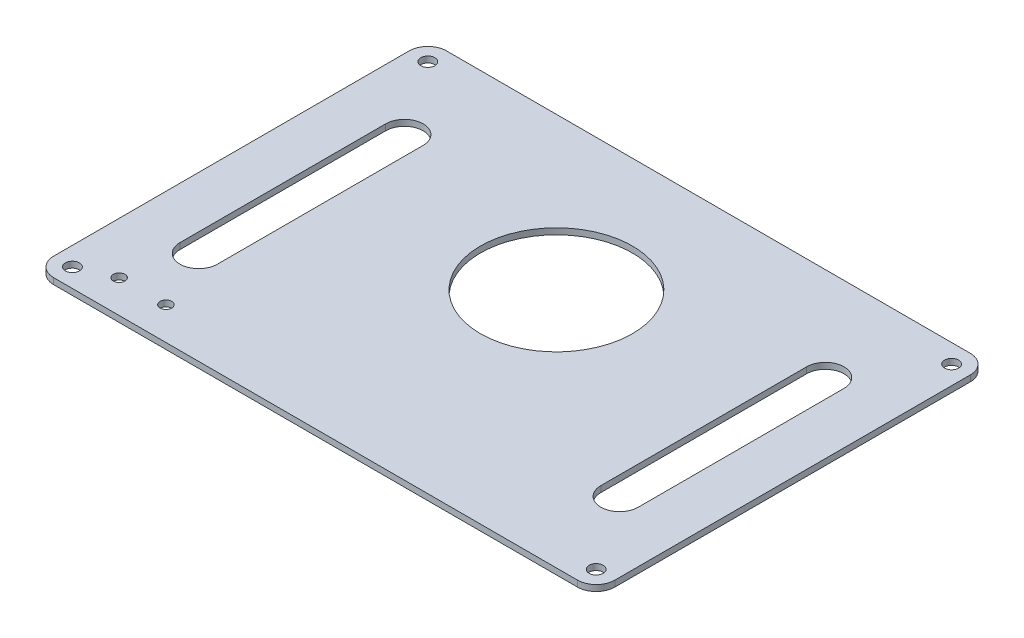
from build123d import *

# Parameters (mm, degrees)
SKETCH1_R           = 1.5
BOSS_EXTRUDE1_DEPTH = 1.3
SKETCH2_R           = 16.25
SKETCH2_R_2         = 1.25
CUT_EXTRUDE1_DEPTH  = 1.3


with BuildPart() as part:
    # Sketch1 → Boss-Extrude1 (new body)
    with BuildSketch(Plane(origin=(0, 0, 0), x_dir=(1, 0, 0), z_dir=(0, 1, 0))):
        with BuildLine():
            Line((-56, -42), (56, -42))
            ThreePointArc((56, -42), (58.828427125, -40.828427125), (60, -38))
            Line((60, -38), (60, 38))
            ThreePointArc((60, 38), (58.828427125, 40.828427125), (56, 42))
            Line((56, 42), (-56, 42))
            ThreePointArc((-56, 42), (-58.828427125, 40.828427125), (-60, 38))
            Line((-60, 38), (-60, -38))
            ThreePointArc((-60, -38), (-58.828427125, -40.828427125), (-56, -42))
        make_face()
        with Locations((-56, 38)):
            Circle(SKETCH1_R, mode=Mode.SUBTRACT)
        with Locations((56, 38)):
            Circle(SKETCH1_R, mode=Mode.SUBTRACT)
        with Locations((56, -38)):
            Circle(SKETCH1_R, mode=Mode.SUBTRACT)
        with Locations((-56, -38)):
            Circle(SKETCH1_R, mode=Mode.SUBTRACT)
    extrude(amount=BOSS_EXTRUDE1_DEPTH)

    # Sketch2 → Cut-Extrude1 (cut)
    with BuildSketch(Plane(origin=(0, 1.3, 0), x_dir=(1, 0, 0), z_dir=(0, 1, 0))):
        with Locations((0, 9.5)):
            Circle(SKETCH2_R)
        with Locations((-49, -35)):
            Circle(SKETCH2_R_2)
        with Locations((-39, -35)):
            Circle(SKETCH2_R_2)
        with BuildLine():
            Line((-49, 22), (-49, -22))
            ThreePointArc((-49, -22), (-45, -26), (-41, -22))
            Line((-41, -22), (-41, 22))
            ThreePointArc((-41, 22), (-45, 26), (-49, 22))
        make_face()
        with BuildLine():
            Line((49, 22), (49, -22))
            ThreePointArc((49, -22), (45, -26), (41, -22))
            Line((41, -22), (41, 22))
            ThreePointArc((41, 22), (45, 26), (49, 22))
        make_face()
    extrude(amount=-CUT_EXTRUDE1_DEPTH, mode=Mode.SUBTRACT)


solid = part.part
